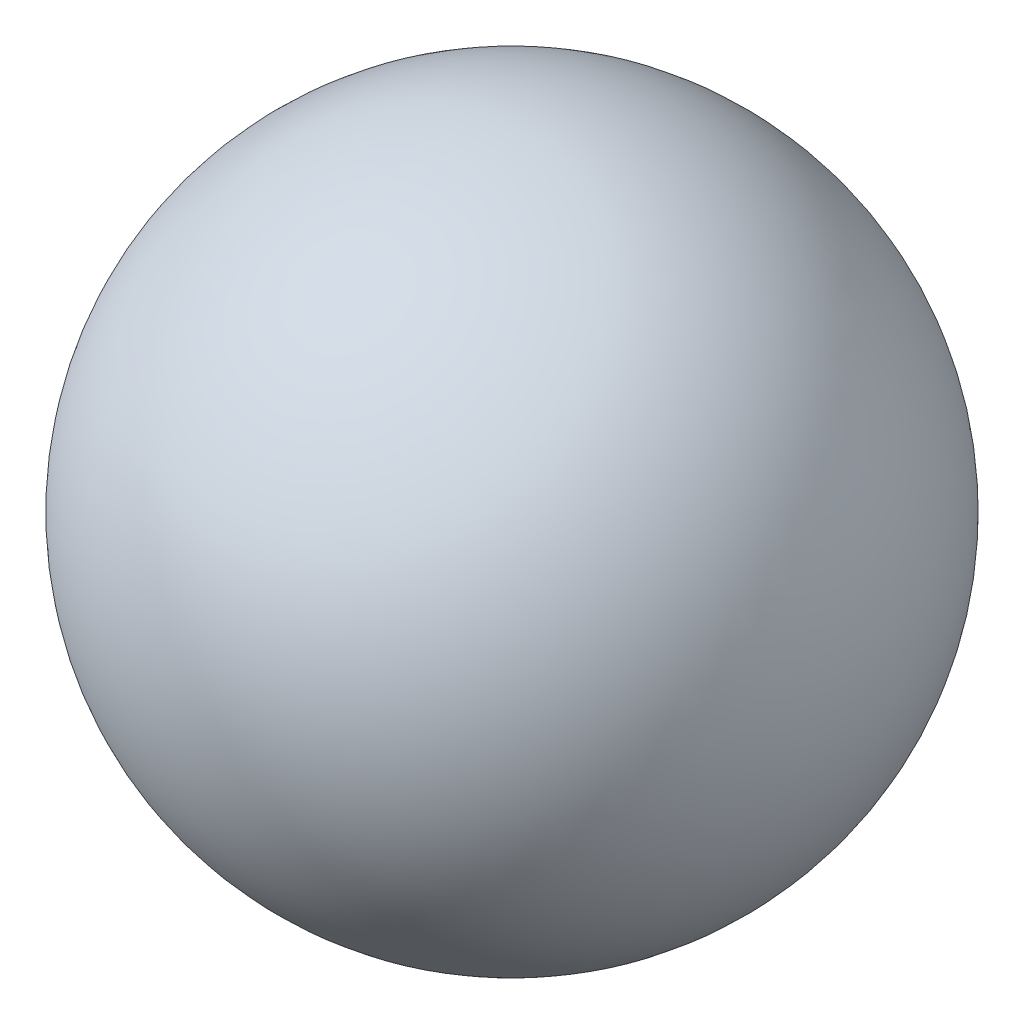
from build123d import *


with BuildPart() as part:
    # Sketch1 → Revolve1 (revolve)
    with BuildSketch(Plane.XY):
        with BuildLine():
            Line((0, -1.094594595), (0, 1.905405405))
            ThreePointArc((0, 1.905405405), (-1.5, 0.405405405), (0, -1.094594595))
        make_face()
    revolve(axis=Axis((0, -1.094594595, 0), (0, 1, 0)))


solid = part.part
